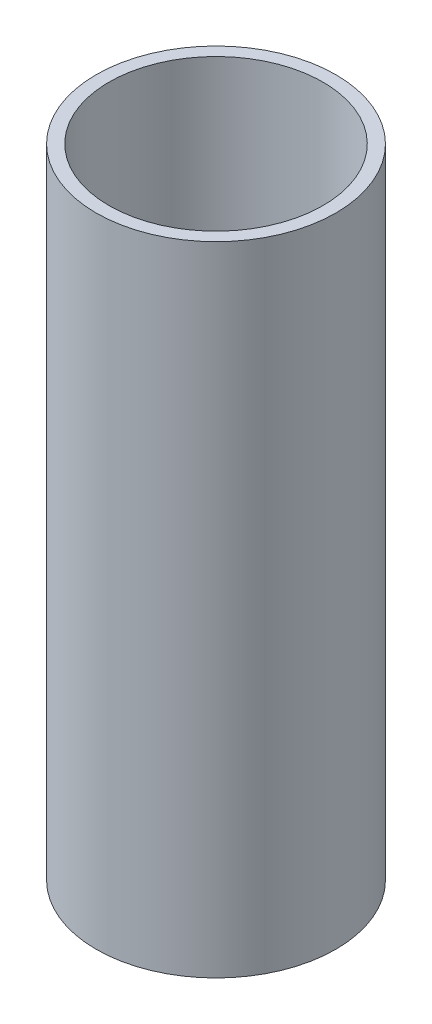
from build123d import *

# Parameters (mm, degrees)
SKETCH1_R           = 14
SKETCH1_R_2         = 12.5
BOSS_EXTRUDE1_DEPTH = 74.498


with BuildPart() as part:
    # Sketch1 → Boss-Extrude1 (new body)
    with BuildSketch(Plane(origin=(0, 0, 0), x_dir=(1, 0, 0), z_dir=(0, 1, 0))):
        Circle(SKETCH1_R)
        Circle(SKETCH1_R_2, mode=Mode.SUBTRACT)
    extrude(amount=BOSS_EXTRUDE1_DEPTH)


solid = part.part
